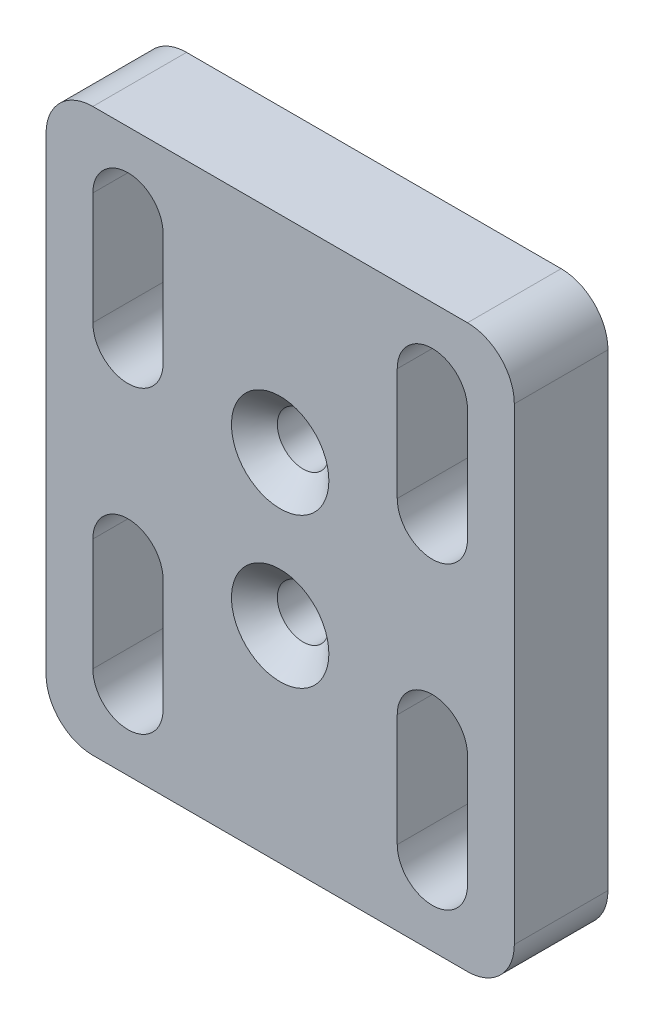
from build123d import *

# Parameters (mm, degrees)
SKETCH1_W                                     = 50
SKETCH1_H                                     = 60
BOSS_EXTRUDE1_DEPTH                           = 10
FILLET1_R                                     = 5
CUT_EXTRUDE1_DEPTH                            = 10
CSK_FOR_M5_COUNTERSUNK_FLAT_HEAD1_D           = 5.5
CSK_FOR_M5_COUNTERSUNK_FLAT_HEAD1_DEPTH       = 30
CSK_FOR_M5_COUNTERSUNK_FLAT_HEAD1_CSINK_D     = 10.4
CSK_FOR_M5_COUNTERSUNK_FLAT_HEAD1_CSINK_ANGLE = 90
CSK_FOR_M5_COUNTERSUNK_FLAT_HEAD1_TIP         = 1.652366702


with BuildPart() as part:
    # Sketch1 → Boss-Extrude1 (new body)
    with BuildSketch(Plane.XY):
        with Locations((25, 30)):
            Rectangle(SKETCH1_W, SKETCH1_H)
    extrude(amount=BOSS_EXTRUDE1_DEPTH)

    # Fillet1
    fillet1_edges = [part.edges().sort_by_distance(p)[0] for p in [
        (0, 60, 5),
        (50, 60, 5),
        (50, 0, 5),
        (0, 0, 5),
    ]]
    fillet(fillet1_edges, radius=FILLET1_R)

    # Sketch2 → Cut-Extrude1 (cut)
    with BuildSketch(Plane.XY.offset(10)):
        with BuildLine():
            Line((12.5, 20), (12.5, 8))
            ThreePointArc((12.5, 8), (8.75, 4.25), (5, 8))
            Line((5, 8), (5, 20))
            ThreePointArc((5, 20), (8.75, 23.75), (12.5, 20))
        make_face()
        with BuildLine():
            Line((37.5, 40), (37.5, 52))
            ThreePointArc((37.5, 52), (41.25, 55.75), (45, 52))
            Line((45, 52), (45, 40))
            ThreePointArc((45, 40), (41.25, 36.25), (37.5, 40))
        make_face()
        with BuildLine():
            Line((37.5, 20), (37.5, 8))
            ThreePointArc((37.5, 8), (41.25, 4.25), (45, 8))
            Line((45, 8), (45, 20))
            ThreePointArc((45, 20), (41.25, 23.75), (37.5, 20))
        make_face()
        with BuildLine():
            Line((12.5, 40), (12.5, 52))
            ThreePointArc((12.5, 52), (8.75, 55.75), (5, 52))
            Line((5, 52), (5, 40))
            ThreePointArc((5, 40), (8.75, 36.25), (12.5, 40))
        make_face()
    extrude(amount=-CUT_EXTRUDE1_DEPTH, mode=Mode.SUBTRACT)

    # CSK for M5 Countersunk Flat Head1
    with Locations(Plane.XY.offset(10)):
        with Locations((25, 38), (25, 22)):
            CounterSinkHole(CSK_FOR_M5_COUNTERSUNK_FLAT_HEAD1_D / 2, CSK_FOR_M5_COUNTERSUNK_FLAT_HEAD1_CSINK_D / 2, depth=CSK_FOR_M5_COUNTERSUNK_FLAT_HEAD1_DEPTH, counter_sink_angle=CSK_FOR_M5_COUNTERSUNK_FLAT_HEAD1_CSINK_ANGLE)
            with Locations((0, 0, -(CSK_FOR_M5_COUNTERSUNK_FLAT_HEAD1_DEPTH + CSK_FOR_M5_COUNTERSUNK_FLAT_HEAD1_TIP / 2))):  # 118° drill point
                Cone(0, CSK_FOR_M5_COUNTERSUNK_FLAT_HEAD1_D / 2, CSK_FOR_M5_COUNTERSUNK_FLAT_HEAD1_TIP, mode=Mode.SUBTRACT)


solid = part.part
